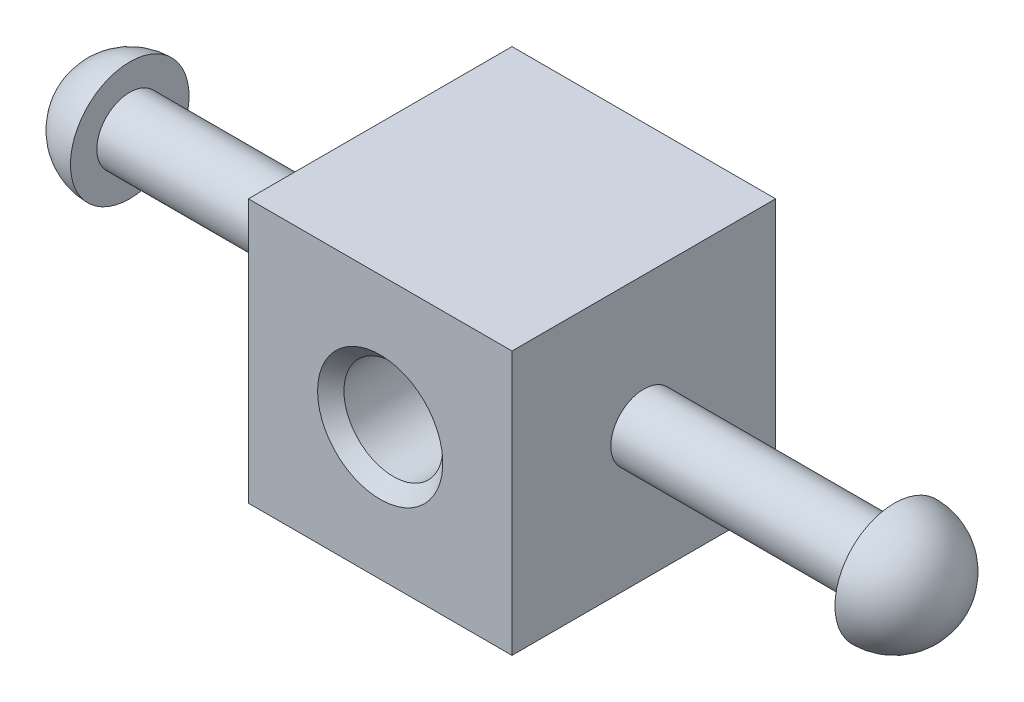
from build123d import *

# Parameters (mm, degrees)
SKETCH2_W           = 25.4
SKETCH2_H           = 25.4
BOSS_EXTRUDE1_DEPTH = 12.7
SKETCH3_R           = 4.7625
CUT_EXTRUDE1_DEPTH  = 26.4
CHAMFER1_SIZE       = 1.27


with BuildPart() as part:
    # Sketch1 → Revolve1 (revolve)
    with BuildSketch(Plane.XY):
        with BuildLine():
            Line((5.715, 5.715), (5.715, 3.175))
            Line((5.715, 3.175), (79.375, 3.175))
            Line((79.375, 3.175), (79.375, 5.715))
            ThreePointArc((79.375, 5.715), (83.416115254, 4.041115254), (85.09, 0))
            Line((85.09, 0), (0, 0))
            ThreePointArc((0, 0), (1.673884746, 4.041115254), (5.715, 5.715))
        make_face()
    revolve(axis=Axis((0, 0, 0), (1, 0, 0)))

    # Sketch2 → Boss-Extrude1 (add, symmetric)
    with BuildSketch(Plane.XY):
        with Locations((42.545, 0)):
            Rectangle(SKETCH2_W, SKETCH2_H)
    extrude(amount=BOSS_EXTRUDE1_DEPTH, both=True)

    # Sketch3 → Cut-Extrude1 (cut, through all)
    with BuildSketch(Plane.XY.offset(12.7)):
        with Locations((42.545, 0)):
            Circle(SKETCH3_R)
    extrude(amount=-CUT_EXTRUDE1_DEPTH, mode=Mode.SUBTRACT)

    # Chamfer1
    chamfer1_edges = [part.edges().sort_by_distance(p)[0] for p in [
        (37.7825, 0, -12.7),
        (37.7825, 0, 12.7),
    ]]
    chamfer(chamfer1_edges, length=CHAMFER1_SIZE)


solid = part.part
